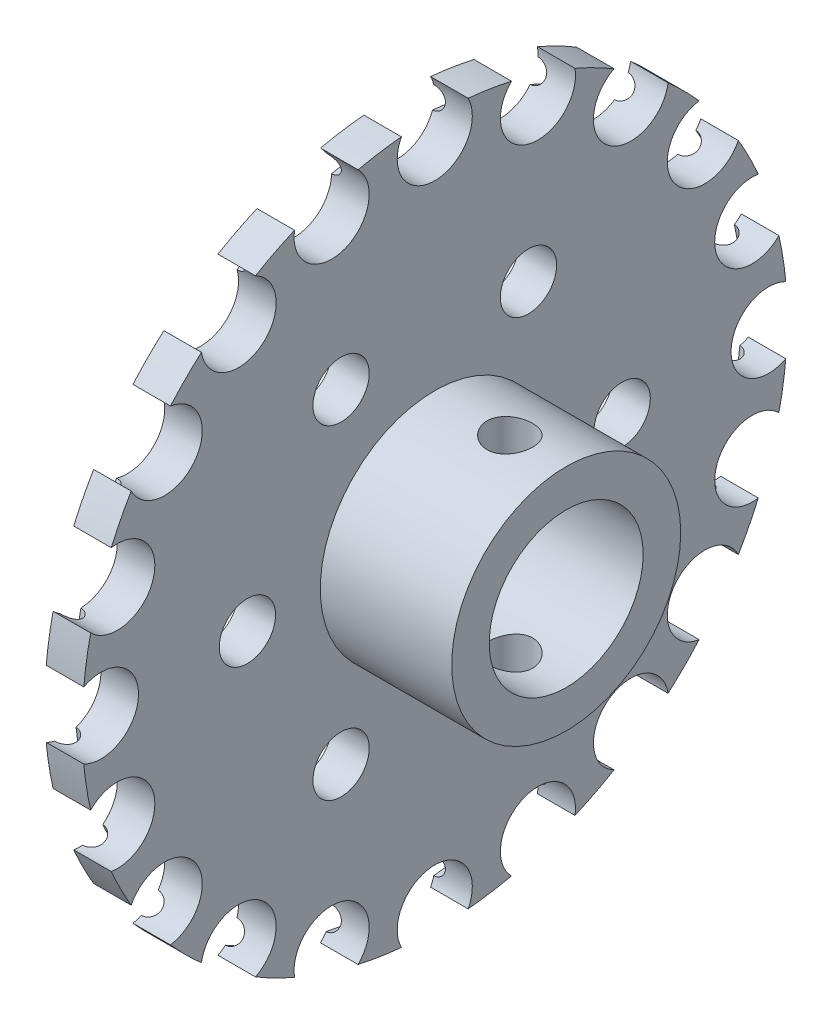
from build123d import *

# Parameters (mm, degrees)
SKETCH2_R           = 18.78
SKETCH2_R_2         = 4.1
BOSS_EXTRUDE1_DEPTH = 1
SKETCH9_R           = 6.1
SKETCH9_R_2         = 4.1
BOSS_EXTRUDE2_DEPTH = 7
SKETCH5_R           = 0.5715
SKETCH10_R          = 1.215
CUT_EXTRUDE1_DEPTH  = 10
CUT_EXTRUDE3_DEPTH  = 10
CIRPATTERN1_COUNT   = 20
SKETCH13_R          = 1.5
CUT_EXTRUDE4_DEPTH  = 10
CIRPATTERN2_COUNT   = 6


with BuildPart() as part:
    # Sketch2 → Boss-Extrude1 (new, symmetric)
    with BuildSketch(Plane(origin=(0, 0, 0), x_dir=(0, 0, -1), z_dir=(1, 0, 0))):
        Circle(SKETCH2_R)
        Circle(SKETCH2_R_2, mode=Mode.SUBTRACT)
    extrude(amount=BOSS_EXTRUDE1_DEPTH, both=True)

    # Sketch9 → Boss-Extrude2 (add)
    with BuildSketch(Plane(origin=(1, 0, 0), x_dir=(0, 0, -1), z_dir=(1, 0, 0))):
        Circle(SKETCH9_R)
        Circle(SKETCH9_R_2, mode=Mode.SUBTRACT)
    extrude(amount=BOSS_EXTRUDE2_DEPTH)

    # Sketch5 → Cut-Revolve1 (revolve, cut)
    with BuildSketch(Plane(origin=(0, 0, 0), x_dir=(1, 0, 0), z_dir=(0, 1, 0))):
        with Locations((-1, -17.78)):
            Circle(SKETCH5_R)
    revolve(axis=Axis((8, 0, 0), (-1, 0, 0)), mode=Mode.SUBTRACT)

    # Sketch10 → Cut-Extrude1 (cut, symmetric)
    with BuildSketch(Plane(origin=(0, 0, 0), x_dir=(1, 0, 0), z_dir=(0, 1, 0))):
        with Locations((5, 0)):
            Circle(SKETCH10_R)
    extrude(amount=CUT_EXTRUDE1_DEPTH, both=True, mode=Mode.SUBTRACT)

    # Sketch12 → Cut-Extrude3 (cut, symmetric)
    with BuildSketch(Plane(origin=(1, 0, 0), x_dir=(0, 0, -1), z_dir=(1, 0, 0))):
        with BuildLine():
            ThreePointArc((-1.778092109, -18.695635546), (0.471071004, -19.723731491), (2, -17.78))
            ThreePointArc((2, -17.78), (-0.471071004, -15.836268509), (-1.778092109, -18.695635546))
        make_face()
    cut_extrude3 = extrude(amount=CUT_EXTRUDE3_DEPTH, both=True, mode=Mode.SUBTRACT)

    # CirPattern1: Cut-Extrude3 ×20 about axis
    cirpattern1_axis = Axis((8, 0, 0), (-1, 0, 0))
    for i in range(1, CIRPATTERN1_COUNT):
        add(cut_extrude3.rotate(cirpattern1_axis, i * 360 / CIRPATTERN1_COUNT), mode=Mode.SUBTRACT)

    # Sketch13 → Cut-Extrude4 (cut)
    with BuildSketch(Plane(origin=(1, 0, 0), x_dir=(0, 0, -1), z_dir=(1, 0, 0))):
        with Locations((-9.980278221, 0)):
            Circle(SKETCH13_R)
    cut_extrude4 = extrude(amount=-CUT_EXTRUDE4_DEPTH, mode=Mode.SUBTRACT)

    # CirPattern2: Cut-Extrude4 ×6 about axis
    cirpattern2_axis = Axis((8, 0, 0), (-1, 0, 0))
    for i in range(1, CIRPATTERN2_COUNT):
        add(cut_extrude4.rotate(cirpattern2_axis, i * 360 / CIRPATTERN2_COUNT), mode=Mode.SUBTRACT)


solid = part.part
